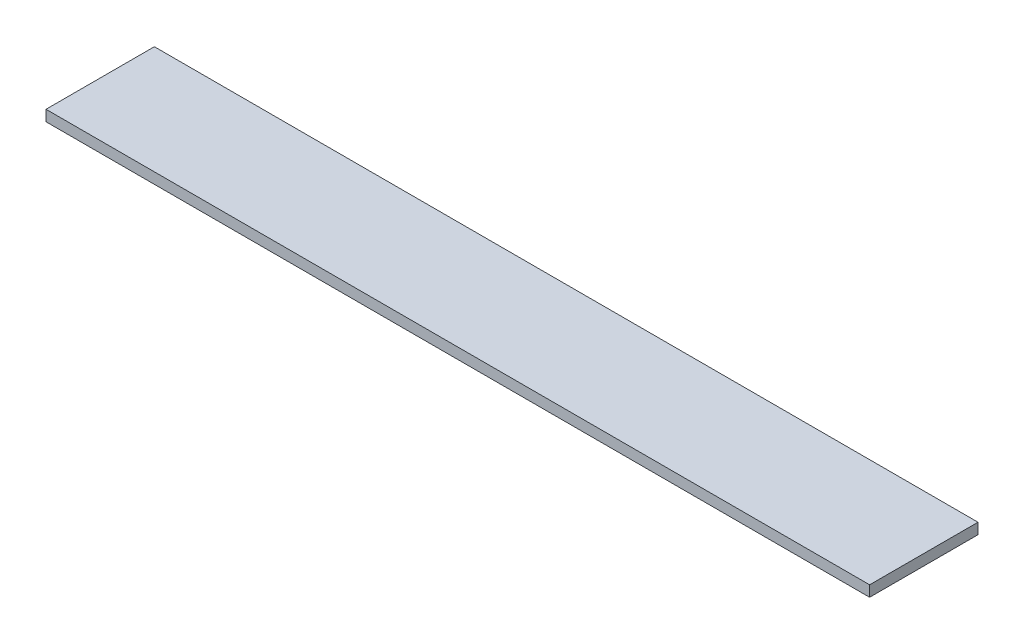
from build123d import *

# Parameters (mm, degrees)
SKETCH1_W           = 760
SKETCH1_H           = 100
BOSS_EXTRUDE1_DEPTH = 10


with BuildPart() as part:
    # Sketch1 → Boss-Extrude1 (new body)
    with BuildSketch(Plane(origin=(0, 0, 0), x_dir=(1, 0, 0), z_dir=(0, 1, 0))):
        Rectangle(SKETCH1_W, SKETCH1_H)
    extrude(amount=BOSS_EXTRUDE1_DEPTH)


solid = part.part
